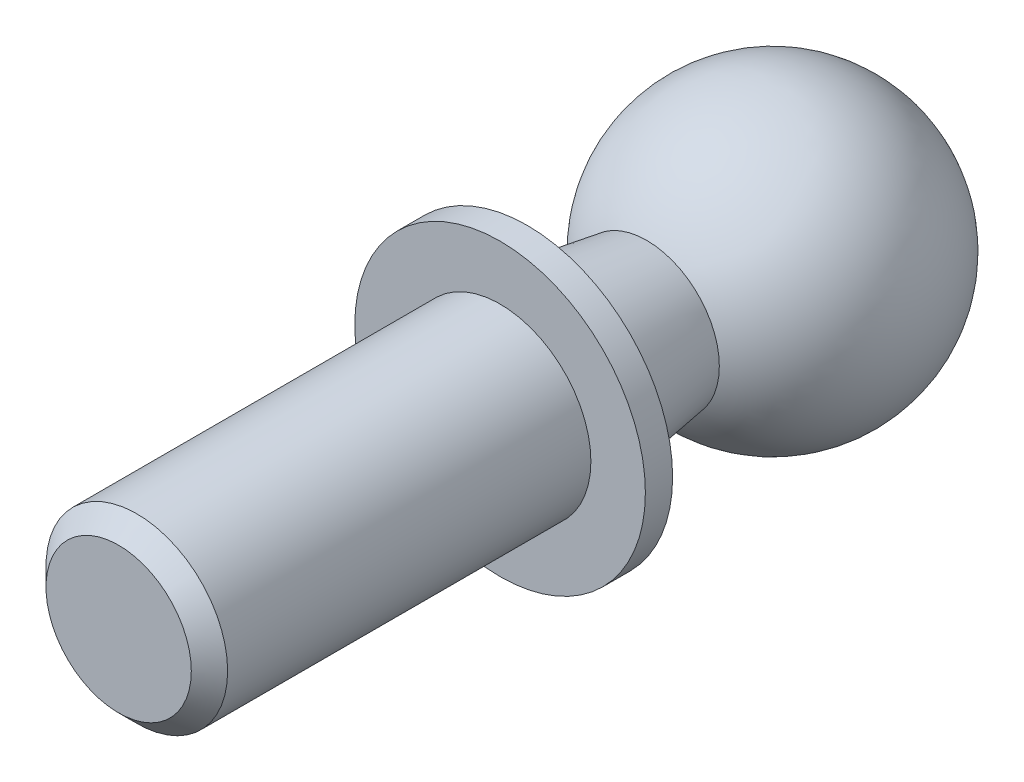
from build123d import *

# Parameters (mm, degrees)
CHAMFER1_SIZE = 1


with BuildPart() as part:
    # Sketch1 → Revolve4 (revolve)
    with BuildSketch(Plane(origin=(0, 0, 0), x_dir=(0, 0, -1), z_dir=(1, 0, 0))):
        with BuildLine():
            Line((-36, 0), (8, 0))
            ThreePointArc((8, 0), (2.070552361, 7.72740661), (-6.92820323, 4))
            Line((-6.92820323, 4), (-13.5, 5))
            Line((-13.5, 5), (-13.5, 8))
            Line((-13.5, 8), (-15, 8))
            Line((-15, 8), (-15, 5))
            Line((-15, 5), (-36, 5))
            Line((-36, 5), (-36, 0))
        make_face()
    revolve(axis=Axis((0, 0, -8), (0, 0, -1)))

    # Chamfer1
    chamfer1_edges = [part.edges().sort_by_distance(p)[0] for p in [
        (0, -5, 36),
    ]]
    chamfer(chamfer1_edges, length=CHAMFER1_SIZE)


solid = part.part
